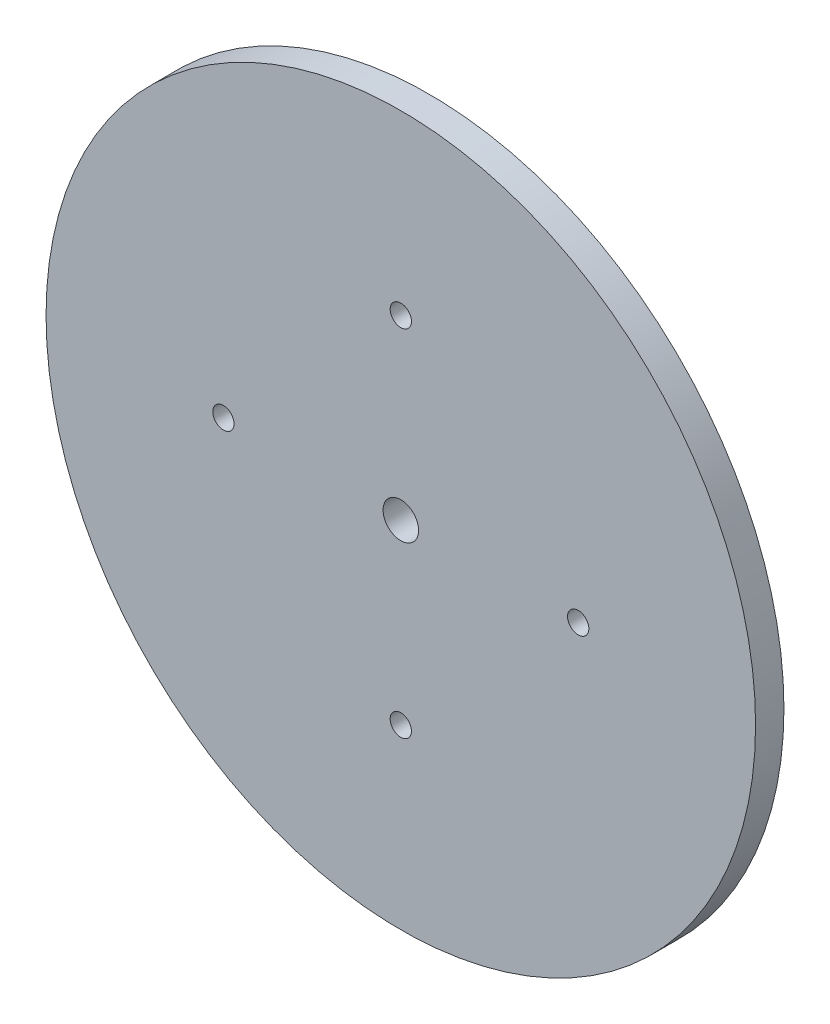
from build123d import *

# Parameters (mm, degrees)
SKETCH1_R           = 50
BOSS_EXTRUDE1_DEPTH = 4
SKETCH4_R           = 2.5
CUT_EXTRUDE1_DEPTH  = 5
SKETCH5_R           = 1.5
CUT_EXTRUDE2_DEPTH  = 4


with BuildPart() as part:
    # Sketch1 → Boss-Extrude1 (new body)
    with BuildSketch(Plane.XY):
        with Locations((-42.286719292, 29.938997259)):
            Circle(SKETCH1_R)
    extrude(amount=BOSS_EXTRUDE1_DEPTH)

    # Sketch4 → Cut-Extrude1 (cut)
    with BuildSketch(Plane.XY.offset(4)):
        with Locations((-42.286719292, 29.938997259)):
            Circle(SKETCH4_R)
    extrude(amount=-CUT_EXTRUDE1_DEPTH, mode=Mode.SUBTRACT)

    # Sketch5 → Cut-Extrude2 (cut)
    with BuildSketch(Plane.XY.offset(4)):
        with Locations((-67.286719292, 29.938997259)):
            Circle(SKETCH5_R)
        with Locations((-42.286719292, 54.938997259)):
            Circle(SKETCH5_R)
        with Locations((-17.286719292, 29.938997259)):
            Circle(SKETCH5_R)
        with Locations((-42.286719292, 4.938997259)):
            Circle(SKETCH5_R)
    extrude(amount=-CUT_EXTRUDE2_DEPTH, mode=Mode.SUBTRACT)


solid = part.part
